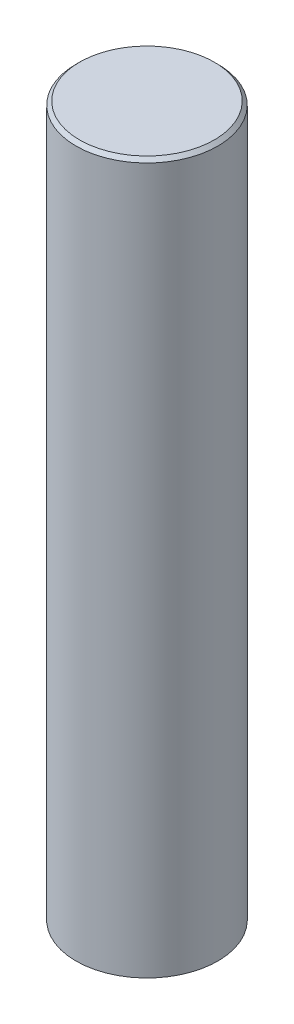
from build123d import *

# Parameters (mm, degrees)
SKETCH1_R           = 20
BOSS_EXTRUDE1_DEPTH = 200
CHAMFER1_SIZE       = 1


with BuildPart() as part:
    # Sketch1 → Boss-Extrude1 (new body)
    with BuildSketch(Plane(origin=(0, 0, 0), x_dir=(1, 0, 0), z_dir=(0, 1, 0))):
        Circle(SKETCH1_R)
    extrude(amount=BOSS_EXTRUDE1_DEPTH)

    # Chamfer1
    chamfer1_edges = [part.edges().sort_by_distance(p)[0] for p in [
        (-20, 200, 0),
    ]]
    chamfer(chamfer1_edges, length=CHAMFER1_SIZE)


solid = part.part
